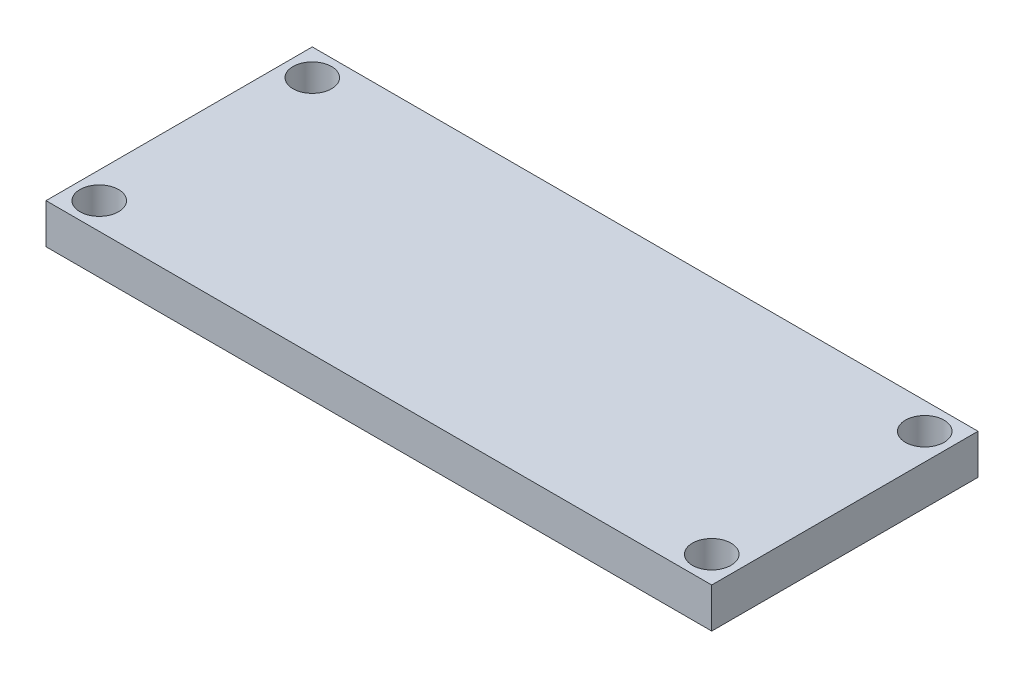
from build123d import *

# Parameters (mm, degrees)
SKETCH1_W                  = 50
SKETCH1_H                  = 20
BOSS_EXTRUDE1_DEPTH        = 3
M2_5_CLEARANCE_HOLE1_D     = 2.9
M2_5_CLEARANCE_HOLE1_DEPTH = 3
M2_5_CLEARANCE_HOLE1_TIP   = 0.871247898


with BuildPart() as part:
    # Sketch1 → Boss-Extrude1 (new body)
    with BuildSketch(Plane(origin=(0, 0, 0), x_dir=(1, 0, 0), z_dir=(0, 1, 0))):
        with Locations((4.014084507, 1.408450704)):
            Rectangle(SKETCH1_W, SKETCH1_H)
    extrude(amount=BOSS_EXTRUDE1_DEPTH)

    # M2.5 Clearance Hole1
    with Locations(Plane(origin=(0, 3, 0), x_dir=(1, 0, 0), z_dir=(0, 1, 0))):
        with Locations((-18.985915493, -6.591549296), (-18.985915493, 9.408450704), (27.014084507, -6.591549296), (27.014084507, 9.408450704)):
            Hole(M2_5_CLEARANCE_HOLE1_D / 2, depth=M2_5_CLEARANCE_HOLE1_DEPTH)
            with Locations((0, 0, -(M2_5_CLEARANCE_HOLE1_DEPTH + M2_5_CLEARANCE_HOLE1_TIP / 2))):  # 118° drill point
                Cone(0, M2_5_CLEARANCE_HOLE1_D / 2, M2_5_CLEARANCE_HOLE1_TIP, mode=Mode.SUBTRACT)


solid = part.part
